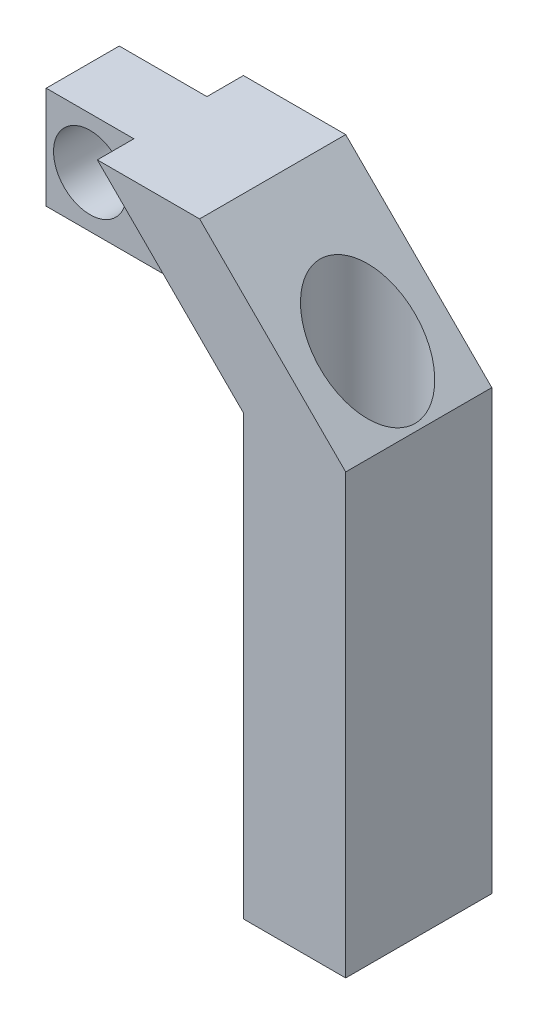
from build123d import *

# Parameters (mm, degrees)
BOSS_EXTRUDE2_DEPTH = 5
SKETCH3_R           = 3.25
CUT_EXTRUDE1_DEPTH  = 11
SKETCH4_W           = 13
SKETCH4_H           = 7
BOSS_EXTRUDE3_DEPTH = 2.5
SKETCH5_R           = 2.5
CUT_EXTRUDE2_DEPTH  = 8.5
SKETCH6_W           = 7
SKETCH6_H           = 10
SKETCH6_R           = 3.25
BOSS_EXTRUDE4_DEPTH = 30


with BuildPart() as part:
    # Sketch2 → Boss-Extrude2 (new body, symmetric)
    with BuildSketch(Plane.XY):
        Polygon((0, 0), (-7, 0), (-17, 10), (-10, 10), align=None)
    extrude(amount=BOSS_EXTRUDE2_DEPTH, both=True)

    # Sketch3 → Cut-Extrude1 (cut, through all)
    with BuildSketch(Plane.XZ):
        with Locations((-3.5, 0)):
            Circle(SKETCH3_R)
    extrude(amount=-CUT_EXTRUDE1_DEPTH, mode=Mode.SUBTRACT)

    # Sketch4 → Boss-Extrude3 (add, symmetric)
    with BuildSketch(Plane.XY):
        with Locations((-16.5, 6.5)):
            Rectangle(SKETCH4_W, SKETCH4_H)
    extrude(amount=BOSS_EXTRUDE3_DEPTH, both=True)

    # Sketch5 → Cut-Extrude2 (cut, through all)
    with BuildSketch(Plane.XY.offset(2.5)):
        with Locations((-20, 6.5)):
            Circle(SKETCH5_R)
    extrude(amount=-CUT_EXTRUDE2_DEPTH, mode=Mode.SUBTRACT)

    # Sketch6 → Boss-Extrude4 (add)
    with BuildSketch(Plane.XZ):
        with Locations((-3.5, 0)):
            Rectangle(SKETCH6_W, SKETCH6_H)
        with Locations((-3.5, 0)):
            Circle(SKETCH6_R, mode=Mode.SUBTRACT)
    extrude(amount=BOSS_EXTRUDE4_DEPTH)


solid = part.part
